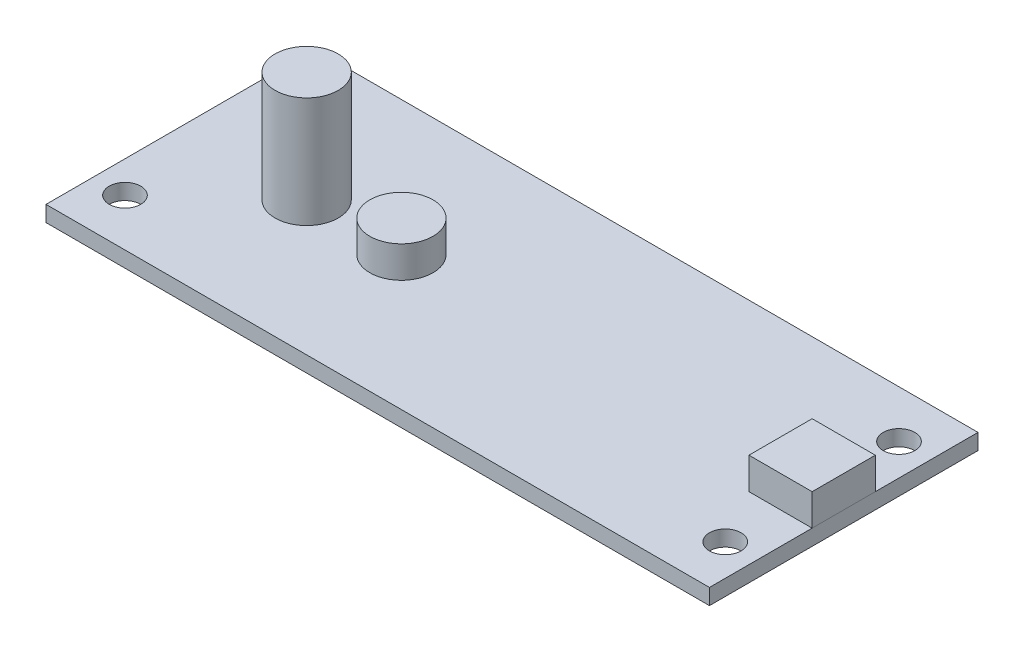
from build123d import *

# Parameters (mm, degrees)
SKETCH1_W             = 66.675
SKETCH1_H             = 26.9875
BOSS_EXTRUDE1_DEPTH   = 1.5875
SKETCH2_R             = 3.175
BOSS_EXTRUDE2_DEPTH   = 11.1125
SKETCH3_R             = 3.175
BOSS_EXTRUDE3_DEPTH   = 3.175
SKETCH3_W             = 6.35
SKETCH3_H             = 6.35
BOSS_EXTRUDE3_2_DEPTH = 3.175
SKETCH4_R             = 1.5875
CUT_EXTRUDE1_DEPTH    = 2.5875


with BuildPart() as part:
    # Sketch1 → Boss-Extrude1 (new body)
    with BuildSketch(Plane(origin=(0, 0, 0), x_dir=(1, 0, 0), z_dir=(0, 1, 0))):
        Rectangle(SKETCH1_W, SKETCH1_H)
    extrude(amount=BOSS_EXTRUDE1_DEPTH)

    # Sketch4 → Cut-Extrude1 (cut, through all)
    with BuildSketch(Plane(origin=(0, 1.5875, 0), x_dir=(1, 0, 0), z_dir=(0, 1, 0))):
        with Locations((30.1625, -8.73125)):
            Circle(SKETCH4_R)
        with Locations((30.1625, 8.73125)):
            Circle(SKETCH4_R)
        with Locations((-30.1625, 8.73125)):
            Circle(SKETCH4_R)
        with Locations((-30.1625, -8.73125)):
            Circle(SKETCH4_R)
    extrude(amount=-CUT_EXTRUDE1_DEPTH, mode=Mode.SUBTRACT)


with BuildPart() as body_2:
    # Sketch2 → Boss-Extrude2 (new body)
    with BuildSketch(Plane(origin=(0, 1.5875, 0), x_dir=(1, 0, 0), z_dir=(0, 1, 0))):
        with Locations((-20.6375, 0)):
            Circle(SKETCH2_R)
    extrude(amount=BOSS_EXTRUDE2_DEPTH)


with BuildPart() as body_3:
    # Sketch3 → Boss-Extrude3 (new body)
    with BuildSketch(Plane(origin=(0, 1.5875, 0), x_dir=(1, 0, 0), z_dir=(0, 1, 0))):
        with Locations((-11.1125, 0)):
            Circle(SKETCH3_R)
    extrude(amount=BOSS_EXTRUDE3_DEPTH)


with BuildPart() as body_4:
    # Sketch3 → Boss-Extrude3 2 (new body)
    with BuildSketch(Plane(origin=(0, 1.5875, 0), x_dir=(1, 0, 0), z_dir=(0, 1, 0))):
        with Locations((30.1625, 0)):
            Rectangle(SKETCH3_W, SKETCH3_H)
    extrude(amount=BOSS_EXTRUDE3_2_DEPTH)


solid = Compound([part.part, body_2.part, body_3.part, body_4.part])
